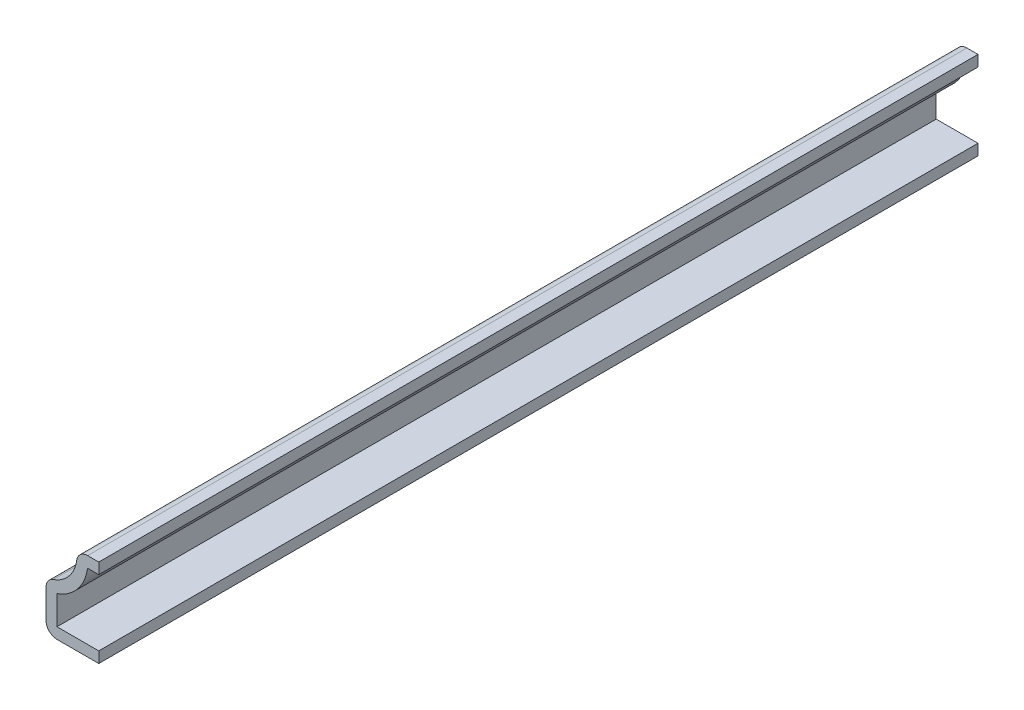
from build123d import *

# Parameters (mm, degrees)
EXTRUDE_THIN1_DEPTH = 158.75
FILLET1_R           = 1.9812


with BuildPart() as part:
    # Sketch1 → Extrude-Thin1 (new body)
    with BuildSketch(Plane.XY):
        with BuildLine():
            Line((0, 0), (-9.525, 0))
            Line((-9.525, 0), (-9.525, 8.73125))
            ThreePointArc((-9.525, 8.73125), (-5.250982158, 11.13965279), (-3.96875, 15.875))
            Line((-3.96875, 15.875), (0, 15.875))
            Line((0, 15.875), (0, 13.8938))
            Line((0, 13.8938), (-2.011138875, 13.8938))
            ThreePointArc((-2.011138875, 13.8938), (-3.827545416, 9.747705801), (-7.5438, 7.163352557))
            Line((-7.5438, 7.163352557), (-7.5438, 1.9812))
            Line((-7.5438, 1.9812), (0, 1.9812))
            Line((0, 1.9812), (0, 0))
        make_face()
    extrude(amount=-EXTRUDE_THIN1_DEPTH)

    # Fillet1
    fillet1_edges = [part.edges().sort_by_distance(p)[0] for p in [
        (-9.525, 0, -79.375),
        (-9.525, 8.73125, -79.375),
        (-3.96875, 15.875, -79.375),
    ]]
    fillet(fillet1_edges, radius=FILLET1_R)


solid = part.part
